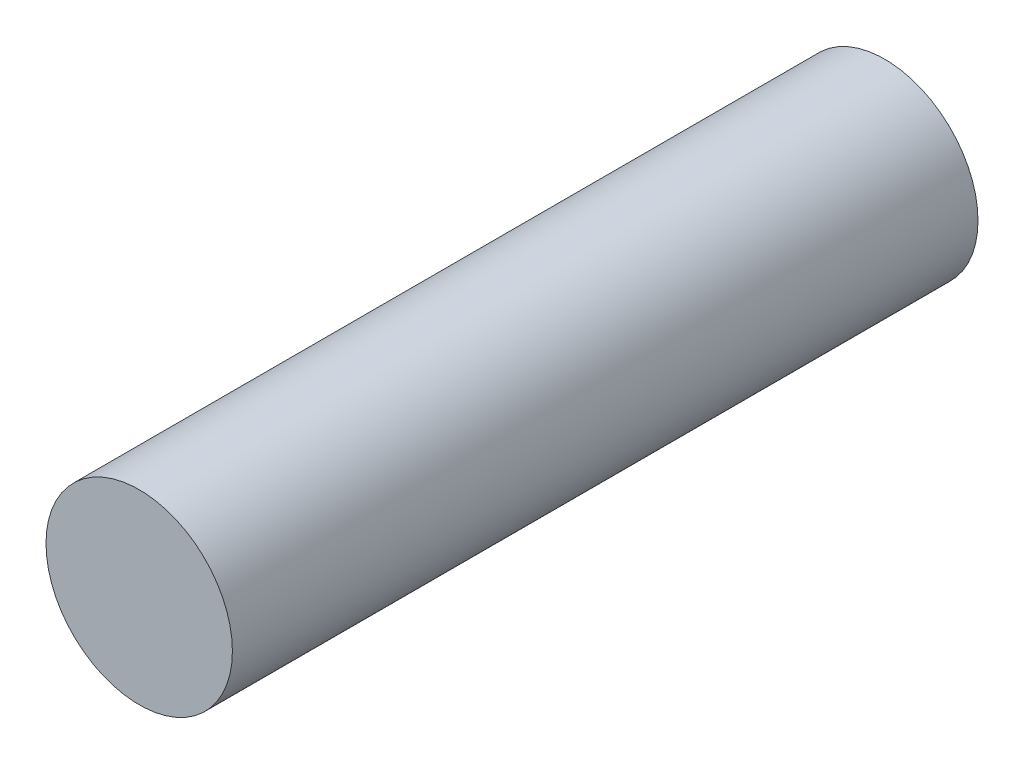
from build123d import *

# Parameters (mm, degrees)
SKETCH2_R           = 1.5
BOSS_EXTRUDE1_DEPTH = 12


with BuildPart() as part:
    # Sketch2 → Boss-Extrude1 (new body)
    with BuildSketch(Plane.XY):
        Circle(SKETCH2_R)
    extrude(amount=BOSS_EXTRUDE1_DEPTH)


solid = part.part
